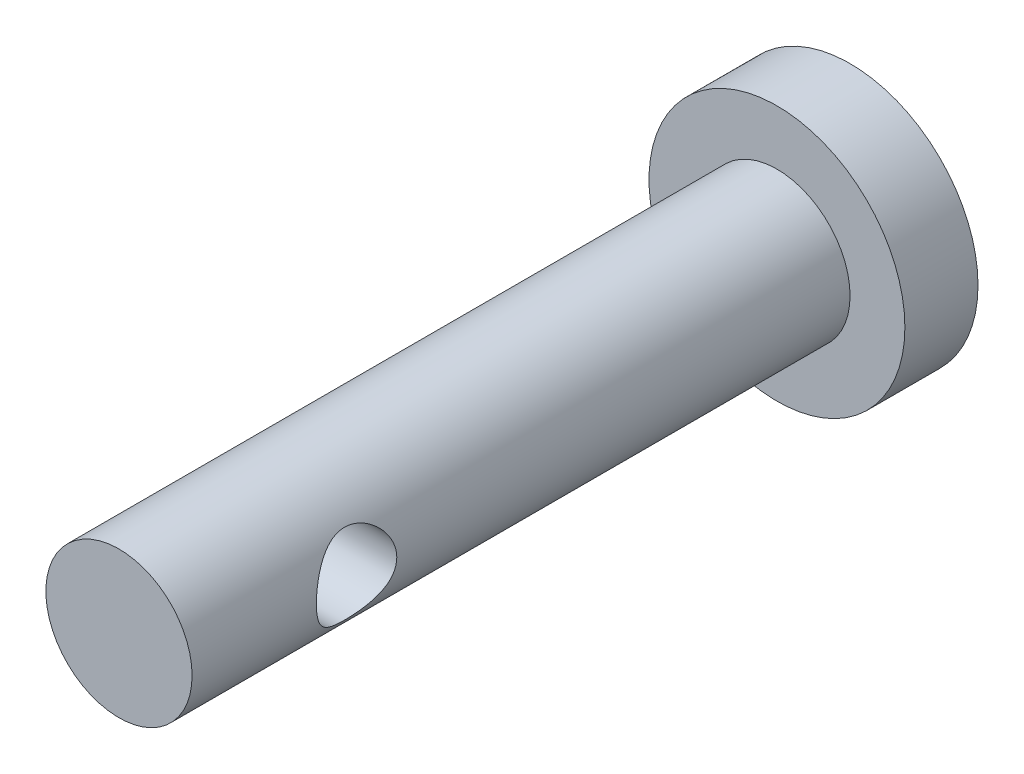
from build123d import *

# Parameters (mm, degrees)
SZKIC1_R                    = 3.5
DODANIE_WYCI_GNI_CIE1_DEPTH = 2
SZKIC2_R                    = 2
DODANIE_WYCI_GNI_CIE2_DEPTH = 18
SZKIC3_R                    = 1.1
WYTNIJ_WYCI_GNI_CIE1_DEPTH  = 6.5


with BuildPart() as part:
    # Szkic1 → Dodanie-wyciągnięcie1 (new body)
    with BuildSketch(Plane.XY):
        Circle(SZKIC1_R)
    extrude(amount=DODANIE_WYCI_GNI_CIE1_DEPTH)

    # Szkic2 → Dodanie-wyciągnięcie2 (add)
    with BuildSketch(Plane.XY.offset(2)):
        Circle(SZKIC2_R)
    extrude(amount=DODANIE_WYCI_GNI_CIE2_DEPTH)

    # Szkic3 → Wytnij-wyciągnięcie1 (cut, through all)
    with BuildSketch(Plane.ZY.offset(2)):
        with Locations((15.5, 0)):
            Circle(SZKIC3_R)
    extrude(amount=-WYTNIJ_WYCI_GNI_CIE1_DEPTH, mode=Mode.SUBTRACT)


solid = part.part
